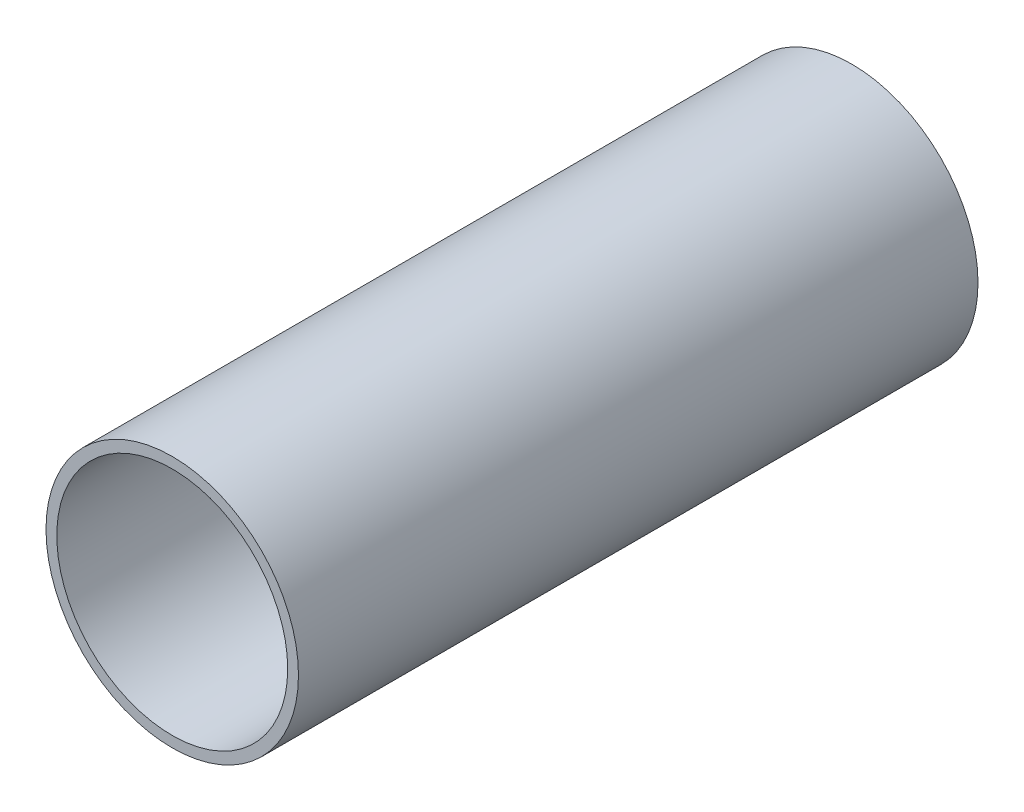
from build123d import *

# Parameters (mm, degrees)
SKETCH1_R           = 84.93125
SKETCH1_R_2         = 77.68125
BOSS_EXTRUDE1_DEPTH = 457.2


with BuildPart() as part:
    # Sketch1 → Boss-Extrude1 (new body)
    with BuildSketch(Plane.XY):
        Circle(SKETCH1_R)
        Circle(SKETCH1_R_2, mode=Mode.SUBTRACT)
    extrude(amount=BOSS_EXTRUDE1_DEPTH)


solid = part.part
